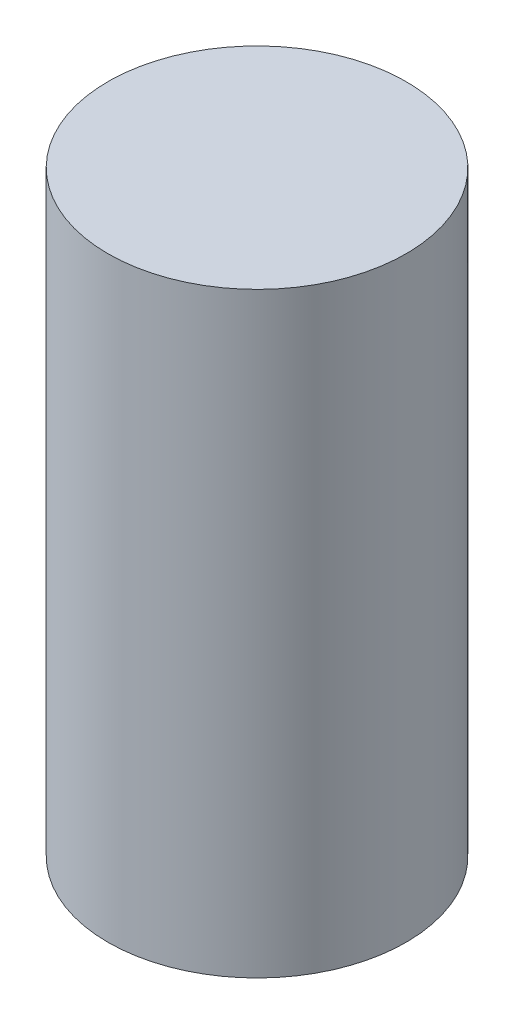
from build123d import *

# Parameters (mm, degrees)
SKETCH_1_R      = 100
EXTRUDE_1_DEPTH = 400


with BuildPart() as part:
    # 草图1 → 凸台-拉伸1 (new body)
    with BuildSketch(Plane(origin=(0, 0, 0), x_dir=(1, 0, 0), z_dir=(0, 1, 0))):
        Circle(SKETCH_1_R)
    extrude(amount=EXTRUDE_1_DEPTH)


solid = part.part
